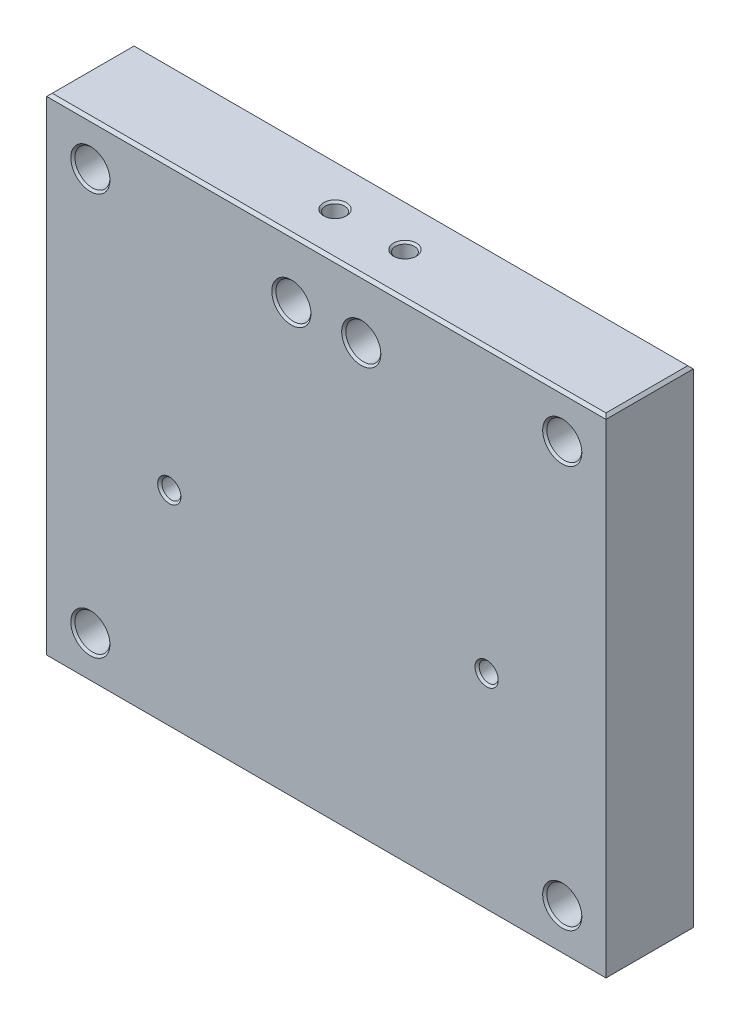
from build123d import *

# Parameters (mm, degrees)
SKETCH1_W                       = 101.6
SKETCH1_H                       = 88.9
BOSS_EXTRUDE1_DEPTH             = 15.875
F_8_32_TAPPED_HOLE1_D           = 3.4544
F_8_32_TAPPED_HOLE1_DEPTH       = 9.652
F_8_32_TAPPED_HOLE1_CSINK_D     = 4.1656
F_8_32_TAPPED_HOLE1_CSINK_ANGLE = 90
F_8_32_TAPPED_HOLE1_TIP         = 1.037806461
F_1_4_0_25_DIAMETER_HOLE1_D     = 6.35
F_1_4_0_25_DIAMETER_HOLE1_DEPTH = 25.4
F_1_4_0_25_DIAMETER_HOLE1_TIP   = 1.907732465
F_8_32_TAPPED_HOLE2_D           = 3.4544
F_9_0_196_DIAMETER_HOLE1_D      = 4.9784
F_9_0_196_DIAMETER_HOLE1_DEPTH  = 12.7
F_9_0_196_DIAMETER_HOLE1_TIP    = 1.495662253
HOLE1_D                         = 6.35
HOLE1_DEPTH                     = 15.875
HOLE1_CBORE_D                   = 9.525
HOLE1_CBORE_DEPTH               = 9.525
HOLE1_TIP                       = 1.907732465
CHAMFER1_SIZE                   = 0.508
CHAMFER2_SIZE                   = 0.381


with BuildPart() as part:
    # Sketch1 → Boss-Extrude1 (new body)
    with BuildSketch(Plane.XY):
        with Locations((-50.8, 44.45)):
            Rectangle(SKETCH1_W, SKETCH1_H)
    extrude(amount=BOSS_EXTRUDE1_DEPTH)

    # #8-32 Tapped Hole1
    with Locations(Plane(origin=(0, 88.9, 0), x_dir=(1, 0, 0), z_dir=(0, 1, 0))):
        with Locations((-44.45, -7.9375), (-57.15, -7.9375)):
            CounterSinkHole(F_8_32_TAPPED_HOLE1_D / 2, F_8_32_TAPPED_HOLE1_CSINK_D / 2, depth=F_8_32_TAPPED_HOLE1_DEPTH, counter_sink_angle=F_8_32_TAPPED_HOLE1_CSINK_ANGLE)
            with Locations((0, 0, -(F_8_32_TAPPED_HOLE1_DEPTH + F_8_32_TAPPED_HOLE1_TIP / 2))):  # 118° drill point
                Cone(0, F_8_32_TAPPED_HOLE1_D / 2, F_8_32_TAPPED_HOLE1_TIP, mode=Mode.SUBTRACT)

    # 1/4 (0.25) Diameter Hole1
    with Locations(Plane.XY.offset(15.875)):
        with Locations((-44.45, 78.210193539), (-57.15, 78.210193539)):
            Hole(F_1_4_0_25_DIAMETER_HOLE1_D / 2, depth=F_1_4_0_25_DIAMETER_HOLE1_DEPTH)
            with Locations((0, 0, -(F_1_4_0_25_DIAMETER_HOLE1_DEPTH + F_1_4_0_25_DIAMETER_HOLE1_TIP / 2))):  # 118° drill point
                Cone(0, F_1_4_0_25_DIAMETER_HOLE1_D / 2, F_1_4_0_25_DIAMETER_HOLE1_TIP, mode=Mode.SUBTRACT)

    # #8-32 Tapped Hole2 (through all)
    with Locations(Plane(origin=(0, 0, 0), x_dir=(-1, 0, 0), z_dir=(0, 0, -1))):
        with Locations((21.675, 37.592), (79.3203, 37.592)):
            Hole(F_8_32_TAPPED_HOLE2_D / 2)

    # #9 (0.196) Diameter Hole1
    with Locations(Plane(origin=(0, 0, 0), x_dir=(-1, 0, 0), z_dir=(0, -1, 0))):
        with Locations((76.2, -7.9375), (25.4, -7.9375)):
            Hole(F_9_0_196_DIAMETER_HOLE1_D / 2, depth=F_9_0_196_DIAMETER_HOLE1_DEPTH)
            with Locations((0, 0, -(F_9_0_196_DIAMETER_HOLE1_DEPTH + F_9_0_196_DIAMETER_HOLE1_TIP / 2))):  # 118° drill point
                Cone(0, F_9_0_196_DIAMETER_HOLE1_D / 2, F_9_0_196_DIAMETER_HOLE1_TIP, mode=Mode.SUBTRACT)

    # Hole1
    with Locations(Plane(origin=(0, 0, 0), x_dir=(1, 0, 0), z_dir=(0, 0, -1))):
        with Locations((-7.9375, -7.9375), (-93.6625, -80.9625), (-93.6625, -7.9375), (-7.9375, -80.9625)):
            CounterBoreHole(HOLE1_D / 2, HOLE1_CBORE_D / 2, HOLE1_CBORE_DEPTH, depth=HOLE1_DEPTH)
            with Locations((0, 0, -(HOLE1_DEPTH + HOLE1_TIP / 2))):  # 118° drill point
                Cone(0, HOLE1_D / 2, HOLE1_TIP, mode=Mode.SUBTRACT)

    # Chamfer1
    chamfer1_edges = [part.edges().sort_by_distance(p)[0] for p in [
        (-50.8, 0, 15.875),
        (-50.8, 0, 0),
        (-50.8, 88.9, 0),
        (-50.8, 88.9, 15.875),
        (0, 0, 7.9375),
        (-101.6, 0, 7.9375),
        (-101.6, 88.9, 7.9375),
        (0, 88.9, 7.9375),
    ]]
    chamfer(chamfer1_edges, length=CHAMFER1_SIZE)

    # Chamfer2
    chamfer2_edges = [part.edges().sort_by_distance(p)[0] for p in [
        (-53.975, 78.210193539, 0),
        (-53.975, 78.210193539, 15.875),
        (-41.275, 78.210193539, 0),
        (-41.275, 78.210193539, 15.875),
        (-23.4022, 37.592, 0),
        (-23.4022, 37.592, 15.875),
        (-81.0475, 37.592, 0),
        (-81.0475, 37.592, 15.875),
        (-12.7, 80.9625, 0),
        (-4.7625, 80.9625, 15.875),
        (-98.425, 7.9375, 0),
        (-90.4875, 7.9375, 15.875),
        (-98.425, 80.9625, 0),
        (-90.4875, 80.9625, 15.875),
        (-12.7, 7.9375, 0),
        (-4.7625, 7.9375, 15.875),
    ]]
    chamfer(chamfer2_edges, length=CHAMFER2_SIZE)


solid = part.part
